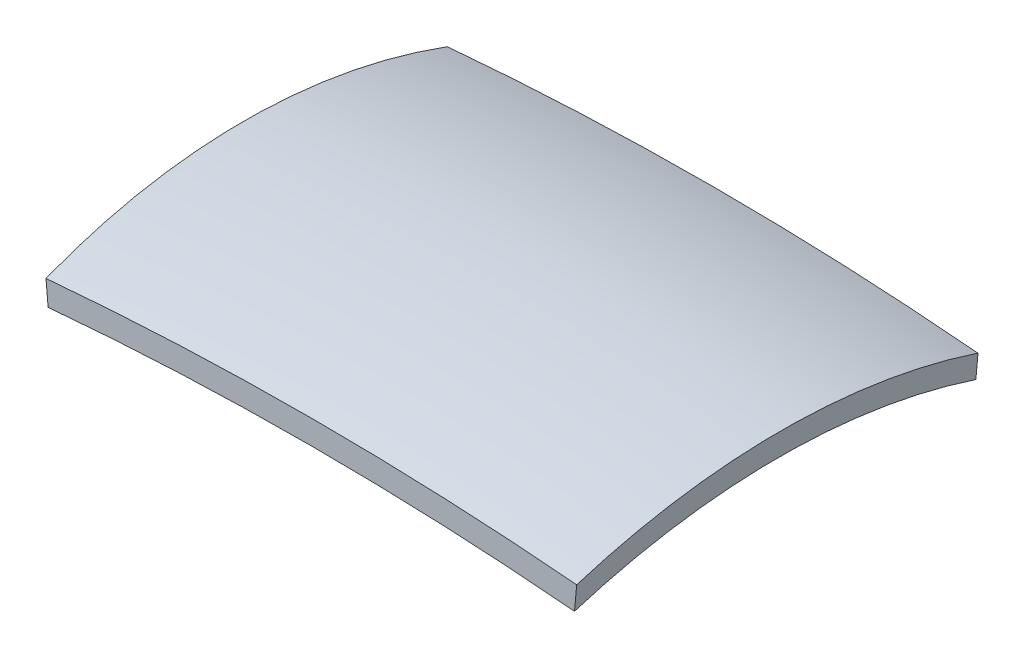
from build123d import *


with BuildPart() as part:
    # Sweep1: sweep along a path in Sketch1
    with BuildLine(Plane.XY) as sweep1_path:
        ThreePointArc((-381.346255507, 0), (274.453744493, 28.976752889), (930.253744493, 0))
    # Sketch2 → Sweep1 (sweep)
    with BuildSketch(Plane(origin=(-381.346255507, 0, 0), x_dir=(0, 0, -1), z_dir=(0.996102918, 0.088198507, 0))):
        with BuildLine():
            Line((1000, 0), (1000, 60))
            ThreePointArc((1000, 60), (500, 145.786437627), (0, 60))
            Line((0, 60), (0, 0))
            ThreePointArc((0, 0), (500, 85.786437627), (1000, 0))
        make_face()
    sweep(path=sweep1_path.line)


solid = part.part
